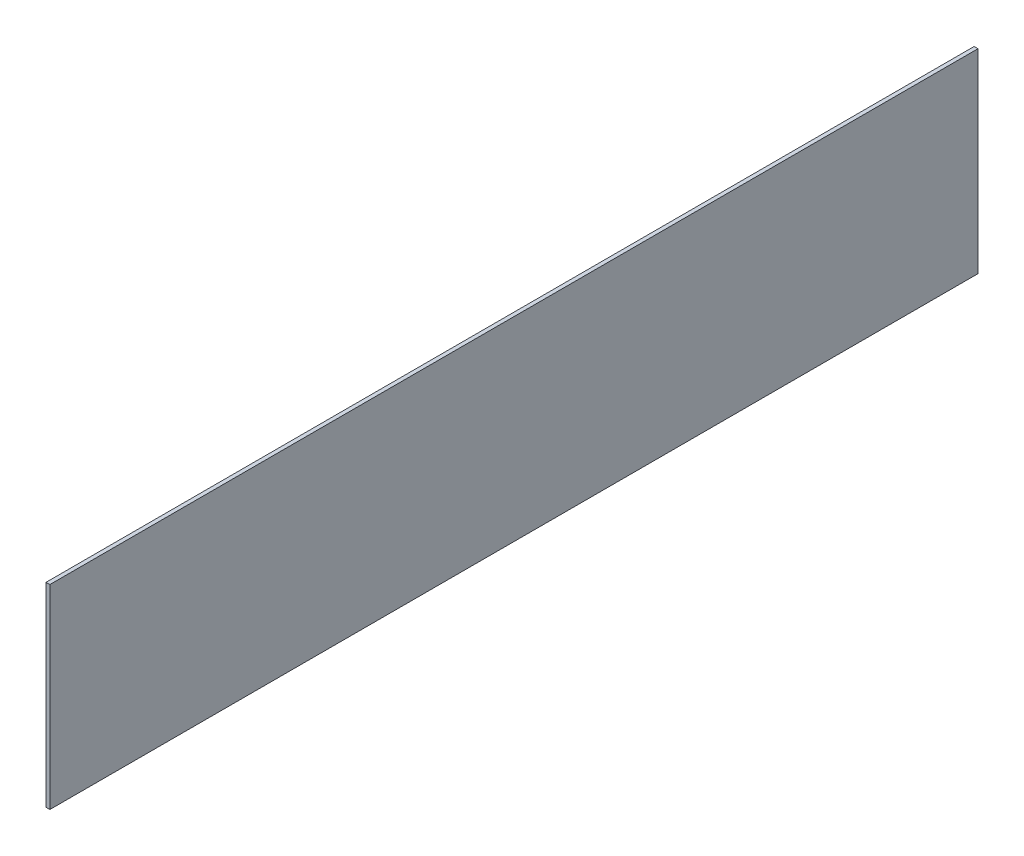
from build123d import *

# Parameters (mm, degrees)
SKETCH1_W           = 302.480000068
SKETCH1_H           = 63.5
BOSS_EXTRUDE1_DEPTH = 0.62865


with BuildPart() as part:
    # Sketch1 → Boss-Extrude1 (new body, symmetric)
    with BuildSketch(Plane(origin=(0, 0, 0), x_dir=(0, 0, -1), z_dir=(1, 0, 0))):
        with Locations((151.240000034, 31.75)):
            Rectangle(SKETCH1_W, SKETCH1_H)
    extrude(amount=BOSS_EXTRUDE1_DEPTH, both=True)


solid = part.part
